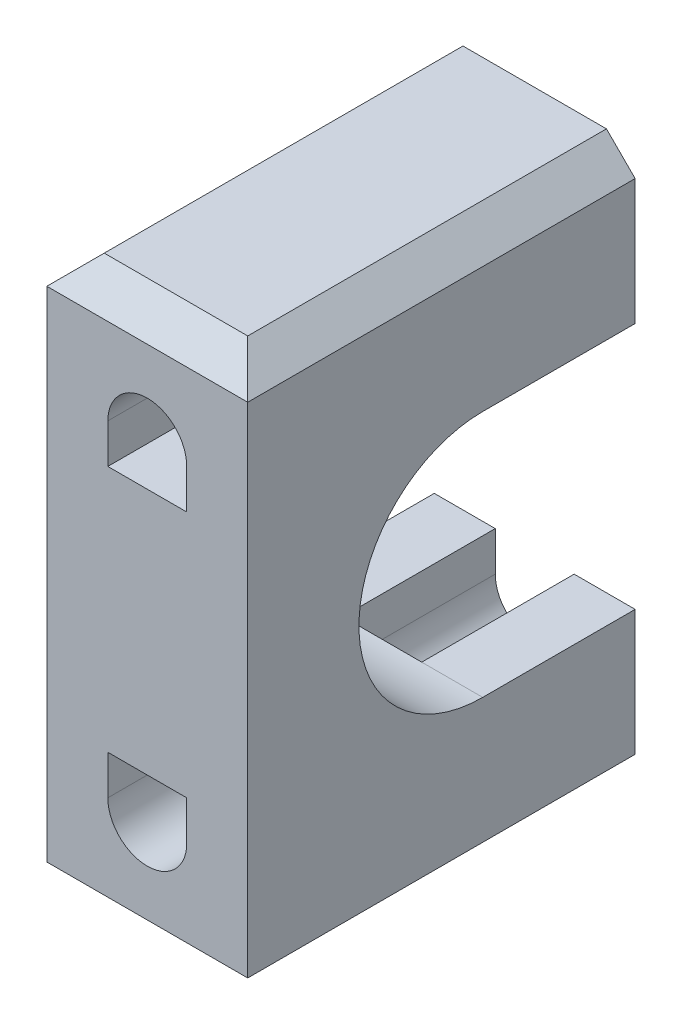
from build123d import *

# Parameters (mm, degrees)
SKETCH1_W           = 14
SKETCH1_H           = 38.75
BOSS_EXTRUDE1_DEPTH = 27
SKETCH2_R           = 8.625
CUT_EXTRUDE1_DEPTH  = 15
CHAMFER1_SIZE       = 2
CHAMFER2_SIZE       = 2


with BuildPart() as part:
    # Sketch1 → Boss-Extrude1 (new body)
    with BuildSketch(Plane.XY):
        Rectangle(SKETCH1_W, SKETCH1_H)
        with BuildLine():
            ThreePointArc((2.75, -11.375), (0, -14.125), (-2.75, -11.375))
            Line((-2.75, -11.375), (-2.75, -8.625))
            Line((-2.75, -8.625), (0, -8.625))
            Line((0, -8.625), (2.75, -8.625))
            Line((2.75, -8.625), (2.75, -11.375))
        make_face(mode=Mode.SUBTRACT)
        with BuildLine():
            Line((-2.75, 8.625), (-2.75, 11.375))
            ThreePointArc((-2.75, 11.375), (0, 14.125), (2.75, 11.375))
            Line((2.75, 11.375), (2.75, 8.625))
            Line((2.75, 8.625), (0, 8.625))
            Line((0, 8.625), (-2.75, 8.625))
        make_face(mode=Mode.SUBTRACT)
    extrude(amount=BOSS_EXTRUDE1_DEPTH)

    # Sketch2 → Cut-Extrude1 (cut, through all)
    with BuildSketch(Plane.ZY.offset(7)):
        with BuildLine():
            ThreePointArc((10.625, -8.625), (2, 0), (10.625, 8.625))
            Line((10.625, 8.625), (0, 8.625))
            Line((0, 8.625), (0, 0))
            Line((0, 0), (0, -8.625))
            Line((0, -8.625), (10.625, -8.625))
        make_face()
        with Locations((10.625, 0)):
            Circle(SKETCH2_R)
    extrude(amount=-CUT_EXTRUDE1_DEPTH, mode=Mode.SUBTRACT)

    # Chamfer1
    chamfer1_edges = [part.edges().sort_by_distance(p)[0] for p in [
        (7, -19.375, 13.5),
        (-7, -19.375, 13.5),
        (-7, 19.375, 13.5),
        (7, 19.375, 13.5),
    ]]
    chamfer(chamfer1_edges, length=CHAMFER1_SIZE)

    # Chamfer2
    chamfer2_edges = [part.edges().sort_by_distance(p)[0] for p in [
        (0, -19.375, 27),
        (0, 19.375, 27),
    ]]
    chamfer(chamfer2_edges, length=CHAMFER2_SIZE)


solid = part.part
